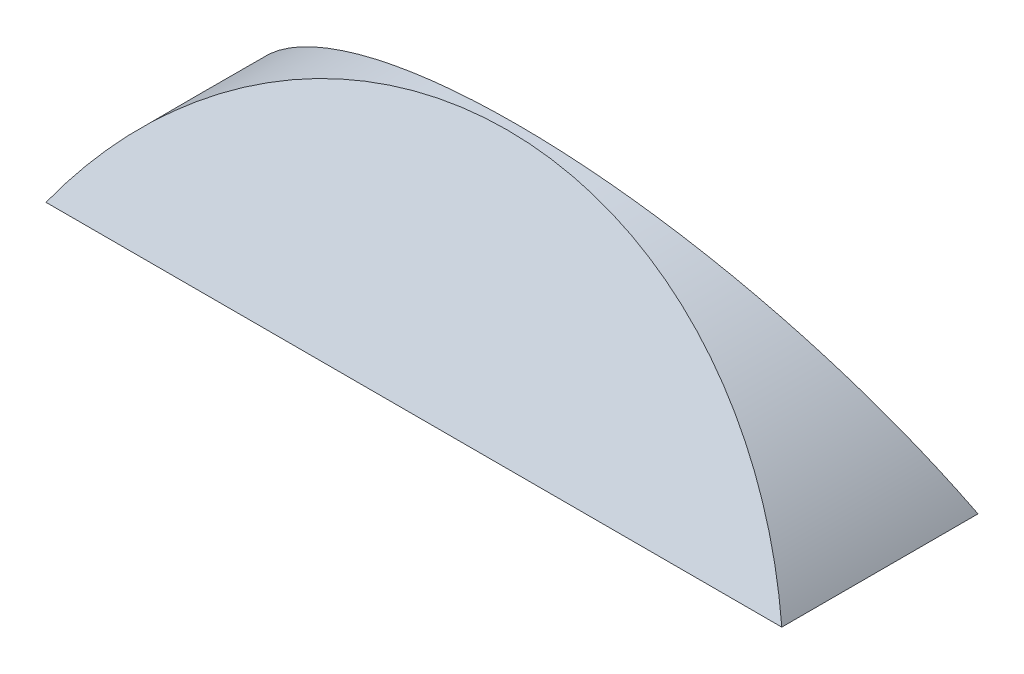
from build123d import *


with BuildPart() as part:
    # Skizze2 → Ausformung1 section 0
    with BuildSketch(Plane(origin=(0, 7.660444431, 16.427876097), x_dir=(1, 0, 0), z_dir=(0, 0.422618262, 0.906307787))):
        with BuildLine():
            Line((-75, -8.452365235), (75, -8.452365235))
            ThreePointArc((75, -8.452365235), (0, 36.547634765), (-75, -8.452365235))
        make_face()
    # Skizze3 → Ausformung1 section 1
    with BuildSketch(Plane(origin=(0, 7.660444431, -16.427876097), x_dir=(1, 0, 0), z_dir=(0, -0.422618262, 0.906307787))):
        with BuildLine():
            Line((-75, -8.452365235), (75, -8.452365235))
            ThreePointArc((75, -8.452365235), (0, 36.547634765), (-75, -8.452365235))
        make_face()
    loft()


solid = part.part
